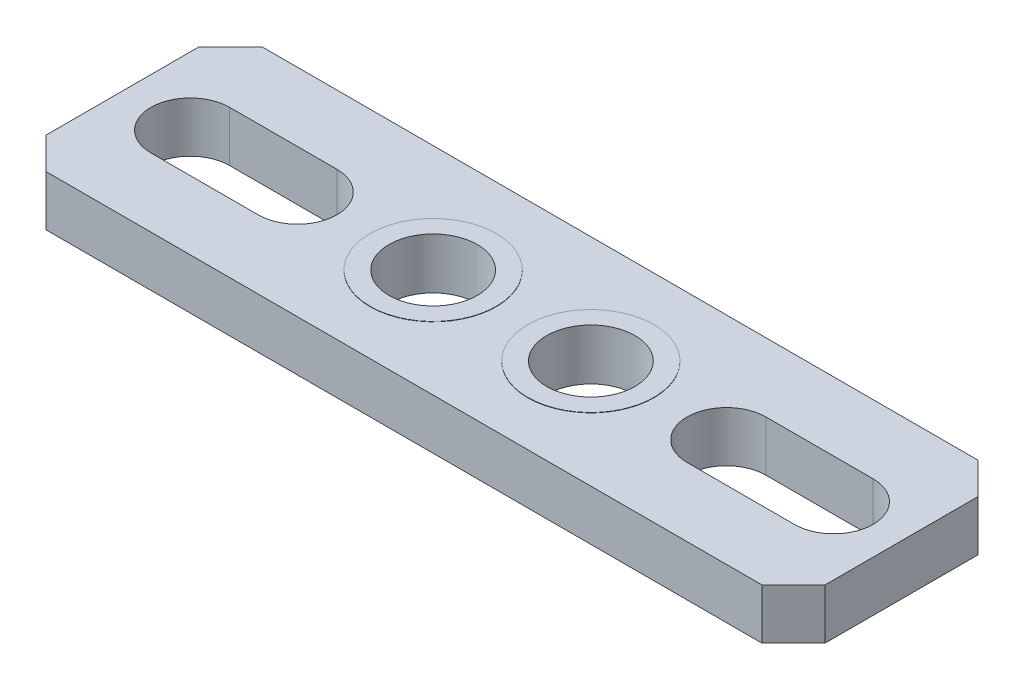
from build123d import *

# Parameters (mm, degrees)
SKETCH1_W           = 24.7
SKETCH1_H           = 6.85
SKETCH1_R           = 1.4
BOSS_EXTRUDE1_DEPTH = 0.8
CHAMFER1_SIZE       = 1
SKETCH2_R           = 2
SKETCH2_R_2         = 1.4
BOSS_EXTRUDE2_DEPTH = 0.01


with BuildPart() as part:
    # Sketch1 → Boss-Extrude1 (new body, symmetric)
    with BuildSketch(Plane(origin=(0, 0, 0), x_dir=(1, 0, 0), z_dir=(0, 1, 0))):
        Rectangle(SKETCH1_W, SKETCH1_H)
        with Locations((-2.5, 0)):
            Circle(SKETCH1_R, mode=Mode.SUBTRACT)
        with Locations((2.5, 0)):
            Circle(SKETCH1_R, mode=Mode.SUBTRACT)
        with BuildLine():
            Line((-10.2, 1.25), (-6.8, 1.25))
            ThreePointArc((-6.8, 1.25), (-5.55, 0), (-6.8, -1.25))
            Line((-6.8, -1.25), (-10.2, -1.25))
            ThreePointArc((-10.2, -1.25), (-11.45, 0), (-10.2, 1.25))
        make_face(mode=Mode.SUBTRACT)
        with BuildLine():
            Line((10.2, 1.25), (6.8, 1.25))
            ThreePointArc((6.8, 1.25), (5.55, 0), (6.8, -1.25))
            Line((6.8, -1.25), (10.2, -1.25))
            ThreePointArc((10.2, -1.25), (11.45, 0), (10.2, 1.25))
        make_face(mode=Mode.SUBTRACT)
    extrude(amount=BOSS_EXTRUDE1_DEPTH, both=True)

    # Chamfer1
    chamfer1_edges = [part.edges().sort_by_distance(p)[0] for p in [
        (12.35, 0, 3.425),
        (-12.35, 0, 3.425),
        (-12.35, 0, -3.425),
        (12.35, 0, -3.425),
    ]]
    chamfer(chamfer1_edges, length=CHAMFER1_SIZE)

    # Sketch2 → Boss-Extrude2 (add)
    with BuildSketch(Plane(origin=(0, 0.8, 0), x_dir=(1, 0, 0), z_dir=(0, 1, 0))):
        with Locations((-2.5, 0)):
            Circle(SKETCH2_R)
        with Locations((-2.5, 0)):
            Circle(SKETCH2_R_2, mode=Mode.SUBTRACT)
        with Locations((2.5, 0)):
            Circle(SKETCH2_R)
        with Locations((2.5, 0)):
            Circle(SKETCH2_R_2, mode=Mode.SUBTRACT)
    boss_extrude2 = extrude(amount=BOSS_EXTRUDE2_DEPTH)

    # Mirror1: Boss-Extrude2 across plane
    add(boss_extrude2.mirror(Plane.ZX))


solid = part.part
